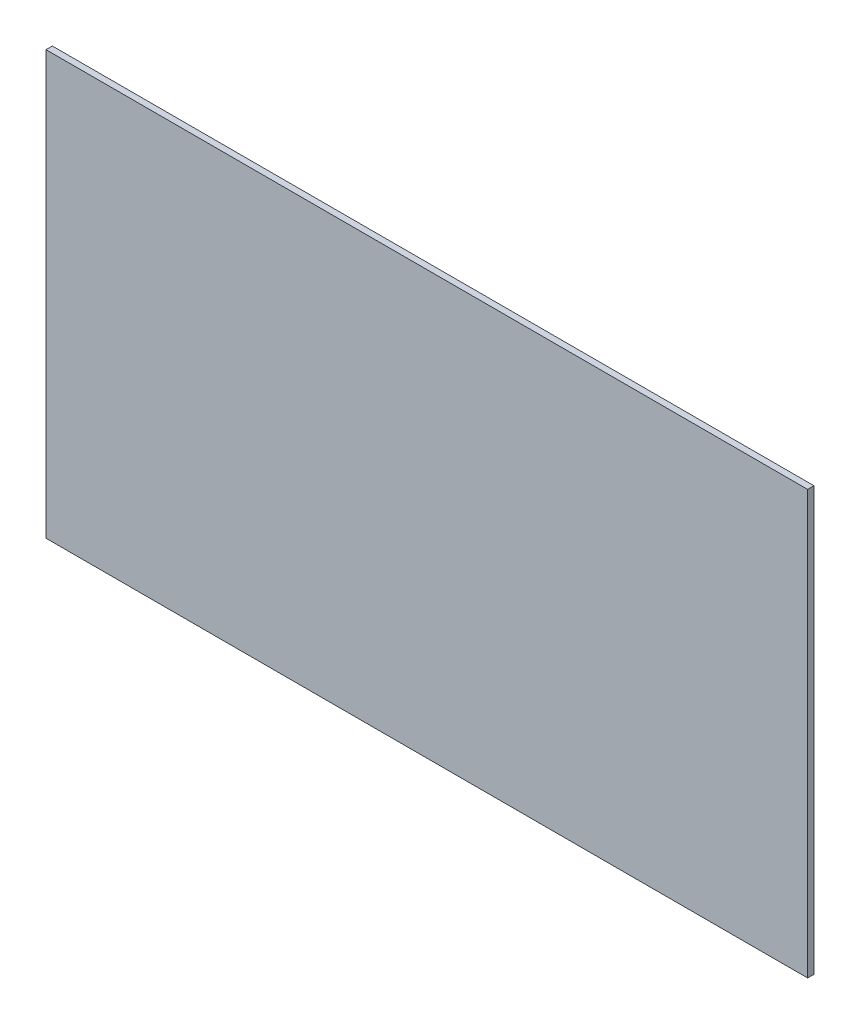
from build123d import *

# Parameters (mm, degrees)
SKETCH_1_W      = 180
SKETCH_1_H      = 100
EXTRUDE_1_DEPTH = 1.5


with BuildPart() as part:
    # 草圖1 → 填料-伸長1 (new body)
    with BuildSketch(Plane.XY):
        with Locations((-30.790388536, 6.497175141)):
            Rectangle(SKETCH_1_W, SKETCH_1_H)
    extrude(amount=EXTRUDE_1_DEPTH)


solid = part.part
